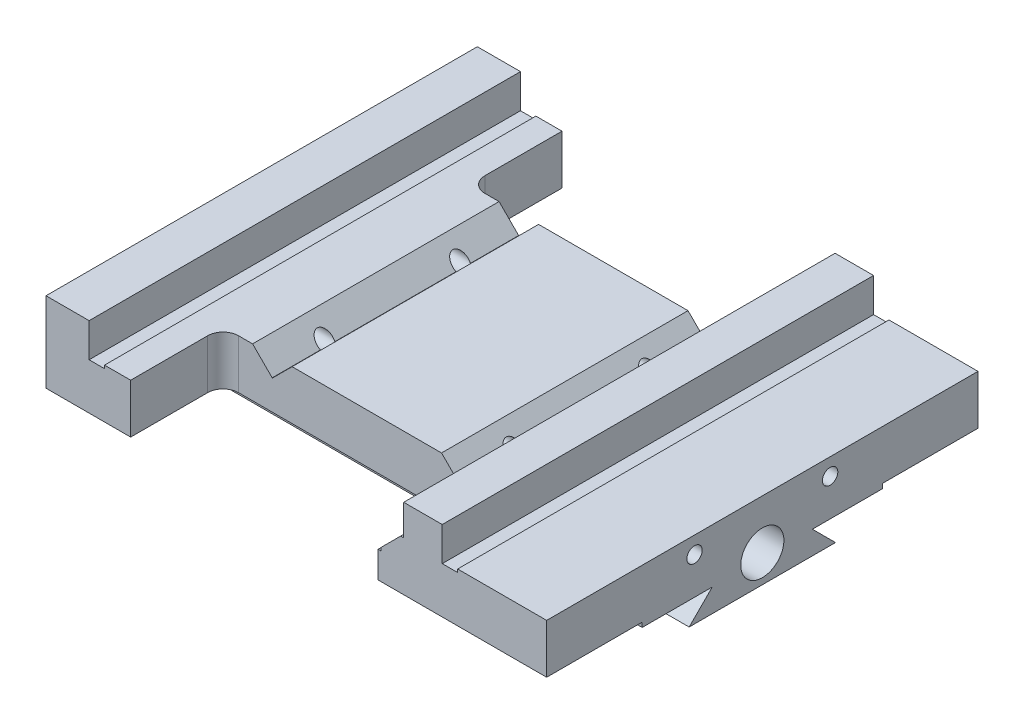
from build123d import *

# Parameters (mm, degrees)
BOSS_EXTRUDE1_DEPTH = 140
BOSS_EXTRUDE2_DEPTH = 162.5
CUT_EXTRUDE1_DEPTH  = 100
SKETCH4_R           = 7
CUT_EXTRUDE2_DEPTH  = 1000
SKETCH5_R           = 2.5
CUT_EXTRUDE3_DEPTH  = 1000


with BuildPart() as part:
    # Sketch1 → Boss-Extrude1 (new body)
    with BuildSketch(Plane.XY):
        Polygon((-148.823444479, 16.363961031), (-134.823444479, 16.363961031), (-134.823444479, 6.363961031), (-134.823444479, 5.363961031), (-129.823444479, 5.363961031), (-129.823444479, 6.363961031), (-111.771895875, 6.363961031), (-105.407934844, 0), (-105.307934844, 0), (-98.943973814, 6.363961031), (-50.443973814, 6.363961031), (-44.080012783, 0), (-44.080012783, -1), (-40.080012783, -1), (-40.080012783, 0), (-33.716051752, 6.363961031), (-32.716051752, 6.363961031), (-32.716051752, 16.363961031), (-20.216051752, 16.363961031), (-20.216051752, 5.363961031), (-15.216051752, 5.363961031), (-15.216051752, 6.363961031), (13.676555521, 6.363961031), (13.676555521, -9.636038969), (-148.823444479, -9.636038969), align=None)
    extrude(amount=BOSS_EXTRUDE1_DEPTH)

    # Sketch2 → Boss-Extrude2 (add)
    with BuildSketch(Plane(origin=(13.676555521, 0, 0), x_dir=(0, 0, -1), z_dir=(1, 0, 0))):
        Polygon((-86.25, -11.136038969), (-93.75, -18.636038969), (-46.25, -18.636038969), (-53.75, -11.136038969), (-31, -11.136038969), (-31, -8.713113528), (-109, -8.713113528), (-109, -11.136038969), align=None)
    extrude(amount=-BOSS_EXTRUDE2_DEPTH)

    # Sketch3 → Cut-Extrude1 (cut)
    with BuildSketch(Plane.XZ.offset(9.636038969)):
        with BuildLine():
            Line((-121.342924919, 0), (-41.039209534, 0))
            Line((-41.039209534, 0), (-41.039209534, 25))
            ThreePointArc((-41.039209534, 25), (-42.503675628, 28.535533906), (-46.039209534, 30))
            Line((-46.039209534, 30), (-116.342924919, 30))
            ThreePointArc((-116.342924919, 30), (-119.878458825, 28.535533906), (-121.342924919, 25))
            Line((-121.342924919, 25), (-121.342924919, 0))
        make_face()
        with BuildLine():
            Line((-121.342924919, 140), (-41.039209534, 140))
            Line((-41.039209534, 140), (-41.039209534, 115))
            ThreePointArc((-41.039209534, 115), (-42.503675628, 111.464466094), (-46.039209534, 110))
            Line((-46.039209534, 110), (-116.342924919, 110))
            ThreePointArc((-116.342924919, 110), (-119.878458825, 111.464466094), (-121.342924919, 115))
            Line((-121.342924919, 115), (-121.342924919, 140))
        make_face()
    extrude(amount=-CUT_EXTRUDE1_DEPTH, mode=Mode.SUBTRACT)

    # Sketch4 → Cut-Extrude2 (cut)
    with BuildSketch(Plane(origin=(13.676555521, 0, 0), x_dir=(0, 0, -1), z_dir=(1, 0, 0))):
        with Locations((-70, -9.636038969)):
            Circle(SKETCH4_R)
    extrude(amount=-CUT_EXTRUDE2_DEPTH, mode=Mode.SUBTRACT)

    # Sketch5 → Cut-Extrude3 (cut)
    with BuildSketch(Plane(origin=(13.676555521, 0, 0), x_dir=(0, 0, -1), z_dir=(1, 0, 0))):
        with Locations((-92, 0.863961031)):
            Circle(SKETCH5_R)
        with Locations((-48, 0.863961031)):
            Circle(SKETCH5_R)
    extrude(amount=-CUT_EXTRUDE3_DEPTH, mode=Mode.SUBTRACT)


solid = part.part
